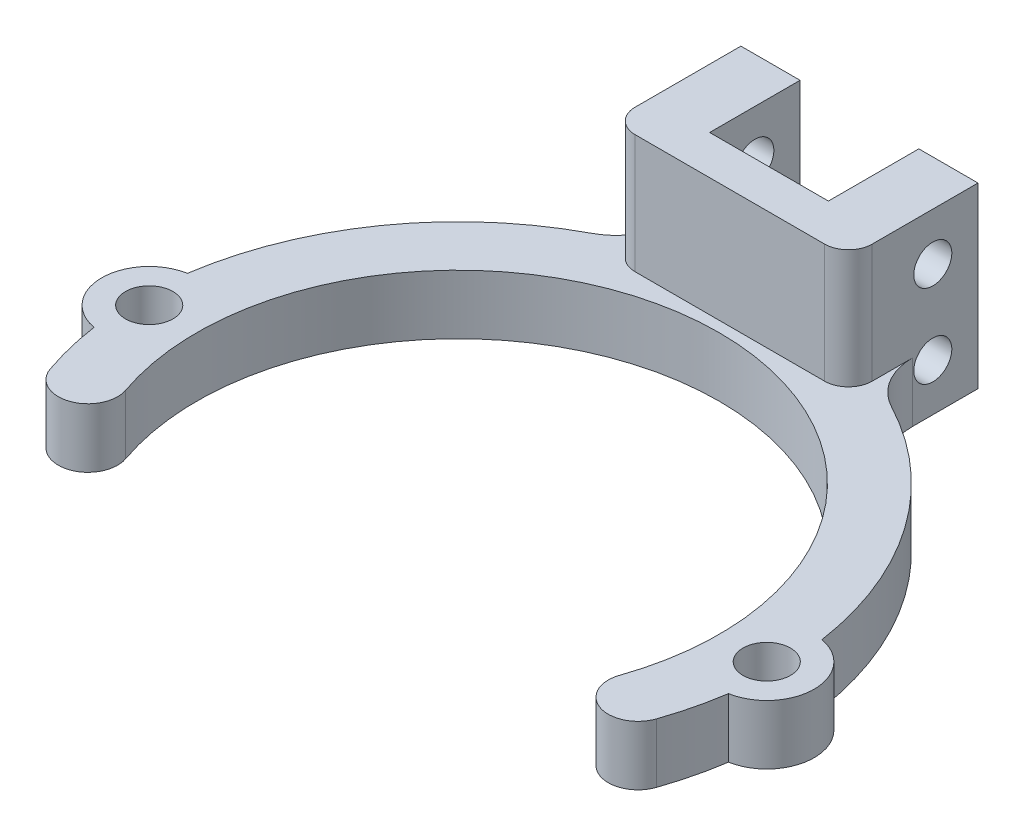
from build123d import *

# Parameters (mm, degrees)
SKETCH_1_R          = 2
EXTRUDE_1_DEPTH     = 5
EXTRUDE_2_DEPTH     = 15
SKETCH_5_W          = 10
SKETCH_5_H          = 7.614001554
CUT_EXTRUDE_2_DEPTH = 6
SKETCH_4_R          = 1.6
CUT_EXTRUDE_1_DEPTH = 40.982946782
FILLET_2_R          = 5
FILLET_3_R          = 2


with BuildPart() as part:
    # 草图1 → 凸台-拉伸1 (new body)
    with BuildSketch(Plane(origin=(0, 0, 0), x_dir=(1, 0, 0), z_dir=(0, 1, 0))):
        with BuildLine():
            ThreePointArc((20.794105787, -7.183673469), (0, 22), (-20.794105787, -7.183673469))
            ThreePointArc((-20.794105787, -7.183673469), (-22.340745823, -10.362966567), (-25.520038921, -8.816326531))
            ThreePointArc((-25.520038921, -8.816326531), (-26.229531343, -6.404036657), (-26.711538462, -3.936205408))
            ThreePointArc((-26.711538462, -3.936205408), (-30, 0), (-26.711538462, 3.936205408))
            ThreePointArc((-26.711538462, 3.936205408), (0, 27), (26.711538462, 3.936205408))
            ThreePointArc((26.711538462, 3.936205408), (30, 0), (26.711538462, -3.936205408))
            ThreePointArc((26.711538462, -3.936205408), (26.229531343, -6.404036657), (25.520038921, -8.816326531))
            ThreePointArc((25.520038921, -8.816326531), (22.340745823, -10.362966567), (20.794105787, -7.183673469))
        make_face()
        with Locations((-26, 0)):
            Circle(SKETCH_1_R, mode=Mode.SUBTRACT)
        with Locations((26, 0)):
            Circle(SKETCH_1_R, mode=Mode.SUBTRACT)
    extrude(amount=EXTRUDE_1_DEPTH)

    # 草图3 → 凸台-拉伸2 (add)
    with BuildSketch(Plane(origin=(0, 0, 0), x_dir=(1, 0, 0), z_dir=(0, 1, 0))):
        Polygon((-5, 33.807000777), (-9.982946782, 33.807000777), (-9.982946782, 22.896387671), (9.982946782, 22.896387671), (9.982946782, 33.807000777), (5, 33.807000777), (5, 26.192999223), (-5, 26.192999223), align=None)
    extrude(amount=EXTRUDE_2_DEPTH)

    # 草图5 → 切除-拉伸2 (cut, through all)
    with BuildSketch(Plane(origin=(0, 5, 0), x_dir=(1, 0, 0), z_dir=(0, 1, 0))):
        with Locations((0, 30)):
            Rectangle(SKETCH_5_W, SKETCH_5_H)
    extrude(amount=-CUT_EXTRUDE_2_DEPTH, mode=Mode.SUBTRACT)

    # 草图4 → 切除-拉伸1 (cut, through all)
    with BuildSketch(Plane.ZY.offset(9.982946782)):
        with Locations((-30, 4)):
            Circle(SKETCH_4_R)
        with Locations((-30, 11)):
            Circle(SKETCH_4_R)
    extrude(amount=-CUT_EXTRUDE_1_DEPTH, mode=Mode.SUBTRACT)

    # 圆角2
    fillet_2_edges = [part.edges().sort_by_distance(p)[0] for p in [
        (9.982946782, 2.5, -25.086665254),
        (-9.982946782, 2.5, -25.086665254),
    ]]
    fillet(fillet_2_edges, radius=FILLET_2_R)

    # 圆角3
    fillet_3_edges = [part.edges().sort_by_distance(p)[0] for p in [
        (-9.982946782, 10, -22.896387671),
        (9.982946782, 10, -22.896387671),
    ]]
    fillet(fillet_3_edges, radius=FILLET_3_R)


solid = part.part
